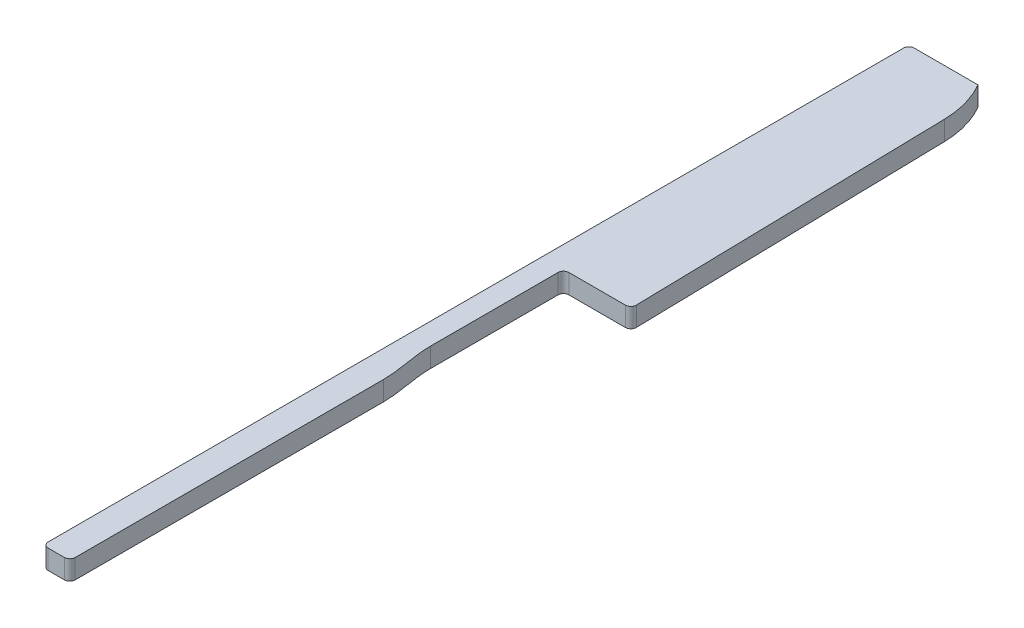
from build123d import *

# Parameters (mm, degrees)
BOSS_EXTRUDE1_DEPTH = 1.8
FILLET2_R           = 0.5
SKETCH3_R           = 2.5
SKETCH3_R_2         = 1.75
BOSS_EXTRUDE2_DEPTH = 1.8
FILLET3_R           = 1
CUT_EXTRUDE1_DEPTH  = 2.8000001
FILLET4_R           = 0.5


with BuildPart() as part:
    # Sketch1 → Boss-Extrude1 (new body)
    with BuildSketch(Plane(origin=(0, 0, 0), x_dir=(1, 0, 0), z_dir=(0, 1, 0))):
        with BuildLine():
            Line((0, 4.5), (0, 6.5))
            Line((0, 6.5), (6.1, 6.5))
            Line((6.1, 6.5), (6.1, 10.5))
            Line((6.1, 10.5), (10, 14.4))
            Line((10, 14.4), (10, 83.5))
            Line((10, 83.5), (16.4, 83.5))
            ThreePointArc((16.4, 83.5), (17.2719581, 81.425344658), (17.601960582, 79.199226044))
            Line((17.601960582, 79.199226044), (18.25, 49.5))
            Line((18.25, 49.5), (12, 49.5))
            Line((12, 49.5), (12, 37.18))
            add(Edge.make_bspline(
                [(12.5, 32.33), (12.5, 33.972282338), (12, 35.554764974), (12, 37.18)],
                knots=[0, 0, 0, 0, 1, 1, 1, 1], degree=3))
            Line((12.5, 32.33), (12.5, 3.07))
            ThreePointArc((12.5, 3.07), (11.600817818, 0.899182182), (9.43, 0))
            ThreePointArc((9.43, 0), (4.205660329, 1.182650422), (0, 4.5))
        make_face()
    extrude(amount=BOSS_EXTRUDE1_DEPTH)

    # Fillet2
    fillet2_edges = [part.edges().sort_by_distance(p)[0] for p in [
        (0, 0.9, -6.5),
        (6.1, 0.9, -6.5),
        (6.1, 0.9, -10.5),
        (10, 0.9, -14.4),
        (10, 0.9, -83.5),
        (18.25, 0.9, -49.5),
        (12, 0.9, -49.5),
    ]]
    fillet(fillet2_edges, radius=FILLET2_R)

    # Sketch3 → Boss-Extrude2 (add)
    with BuildSketch(Plane.XZ):
        with Locations((9.5, 2.499832541)):
            Circle(SKETCH3_R)
        with Locations((9.5, 2.499832541)):
            Circle(SKETCH3_R_2, mode=Mode.SUBTRACT)
        with BuildLine():
            ThreePointArc((11.824045318, 1.578521867), (9.031018815, 0.044215175), (7, 2.499832541))
            Line((7, 2.499832541), (7, -0.245881701))
            ThreePointArc((7, -0.245881701), (8.2087959, -0.061626967), (9.43, 0))
            ThreePointArc((9.43, 0), (10.256451345, -0.113333266), (11.021883517, -0.444965358))
            Line((11.021883517, -0.444965358), (11.824045318, 1.578521867))
        make_face()
        with BuildLine():
            ThreePointArc((9.43, 0), (8.2087959, -0.061626967), (7, -0.245881701))
            Line((7, -0.245881701), (7, -0.500167459))
            Line((7, -0.500167459), (11, -0.500167459))
            Line((11, -0.500167459), (11.021883517, -0.444965358))
            ThreePointArc((11.021883517, -0.444965358), (10.256451345, -0.113333266), (9.43, 0))
        make_face()
    extrude(amount=-BOSS_EXTRUDE2_DEPTH)

    # Fillet3
    fillet3_edges = [part.edges().sort_by_distance(p)[0] for p in [
        (7, 0.9, -0.245881701),
        (11.021883517, 0.9, -0.444965358),
    ]]
    fillet(fillet3_edges, radius=FILLET3_R)

    # Sketch4 → Cut-Extrude1 (cut, through all)
    with BuildSketch(Plane(origin=(0, 1.8, 0), x_dir=(1, 0, 0), z_dir=(0, 1, 0))):
        Polygon((10, 18.881660772), (10, 3.27), (13.61834734, 3.27), (13.61834734, -6.687183429), (-3.427548793, -6.687183429), (-3.427548793, 18.881660772), align=None)
    extrude(amount=-CUT_EXTRUDE1_DEPTH, mode=Mode.SUBTRACT)

    # Fillet4
    fillet4_edges = [part.edges().sort_by_distance(p)[0] for p in [
        (12.5, 0.9, -3.27),
        (10, 0.9, -3.27),
    ]]
    fillet(fillet4_edges, radius=FILLET4_R)


solid = part.part
